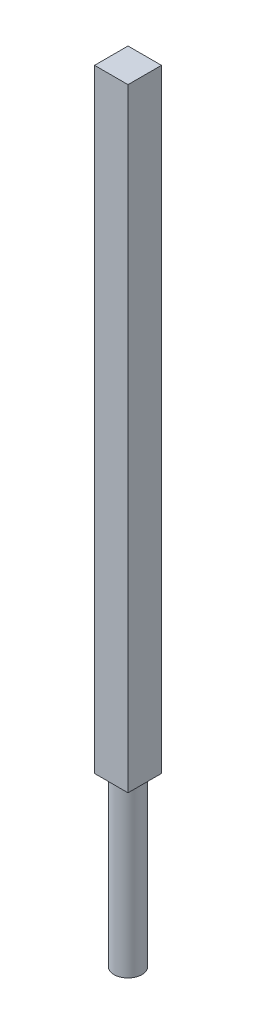
from build123d import *

# Parameters (mm, degrees)
SKETCH1_R           = 12.5
BOSS_EXTRUDE1_DEPTH = 150
SKETCH2_W           = 30
SKETCH2_H           = 30
BOSS_EXTRUDE2_DEPTH = 550


with BuildPart() as part:
    # Sketch1 → Boss-Extrude1 (new body)
    with BuildSketch(Plane(origin=(0, 0, 0), x_dir=(1, 0, 0), z_dir=(0, 1, 0))):
        Circle(SKETCH1_R)
    extrude(amount=BOSS_EXTRUDE1_DEPTH)

    # Sketch2 → Boss-Extrude2 (add)
    with BuildSketch(Plane(origin=(0, 150, 0), x_dir=(1, 0, 0), z_dir=(0, 1, 0))):
        Rectangle(SKETCH2_W, SKETCH2_H)
    extrude(amount=BOSS_EXTRUDE2_DEPTH)


solid = part.part
